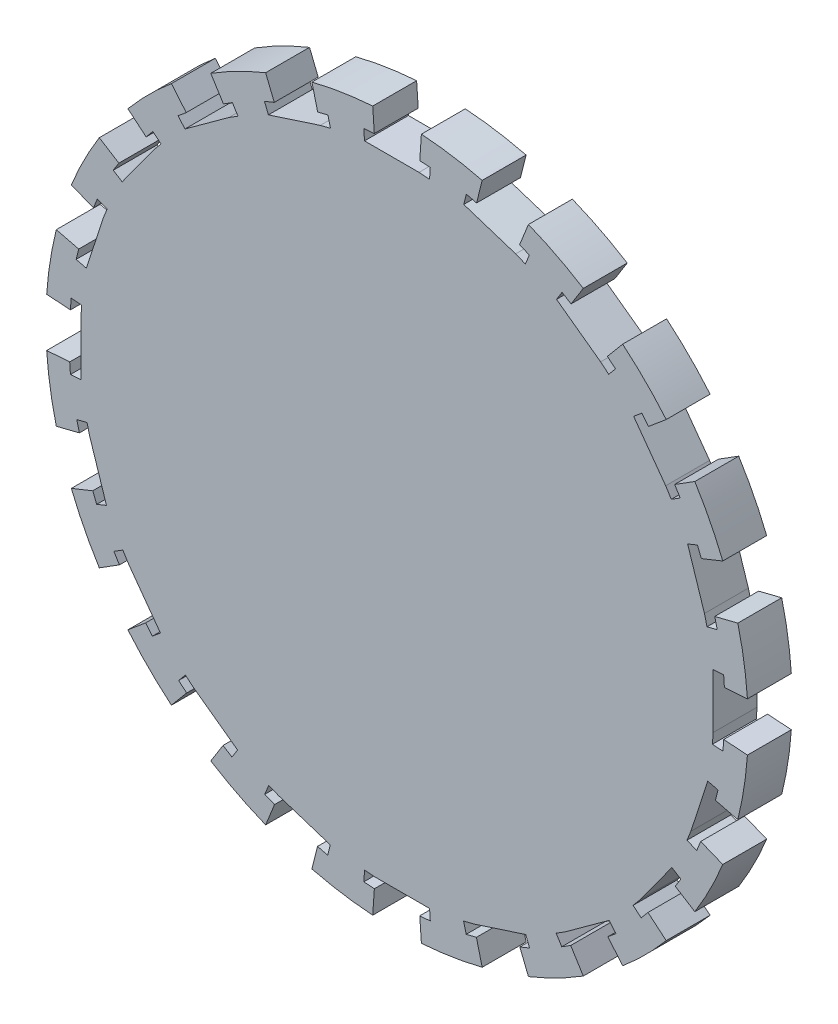
from build123d import *

# Parameters (mm, degrees)
BOSS_EXTRUDE1_DEPTH = 3.175


with BuildPart() as part:
    # Sketch1 → Boss-Extrude1 (new body)
    with BuildSketch(Plane.XY):
        with BuildLine():
            Line((-1.643964299, 23.673085901), (-1.759651006, 25.338974493))
            ThreePointArc((-1.759651006, 25.338974493), (-3.973435412, 25.087283851), (-6.156646182, 24.642558873))
            Line((-6.156646182, 24.642558873), (-5.739470481, 22.972773656))
            Line((-5.739470481, 22.972773656), (-4.998413266, 23.157917865))
            Line((-4.998413266, 23.157917865), (-4.813269057, 22.41686065))
            Line((-4.813269057, 22.41686065), (-5.554326272, 22.231716441))
            Line((-5.554326272, 22.231716441), (-8.573930711, 21.250587484))
            Line((-8.573930711, 21.250587484), (-9.302130689, 21.013980968))
            Line((-9.302130689, 21.013980968), (-9.587241728, 21.720632011))
            Line((-9.587241728, 21.720632011), (-8.878888812, 22.006429701))
            Line((-8.878888812, 22.006429701), (-9.503701294, 23.555034742))
            ThreePointArc((-9.503701294, 23.555034742), (-11.531358693, 22.631565714), (-13.470287947, 21.533957895))
            Line((-13.470287947, 21.533957895), (-12.557538268, 20.074812165))
            Line((-12.557538268, 20.074812165), (-11.909963682, 20.479894045))
            Line((-11.909963682, 20.479894045), (-11.504881803, 19.832319459))
            Line((-11.504881803, 19.832319459), (-12.152456389, 19.427237579))
            Line((-12.152456389, 19.427237579), (-14.721085346, 17.561019403))
            Line((-14.721085346, 17.561019403), (-15.340529246, 17.110967066))
            Line((-15.340529246, 17.110967066), (-15.830053138, 17.694927989))
            Line((-15.830053138, 17.694927989), (-15.244685825, 18.185630833))
            Line((-15.244685825, 18.185630833), (-16.317463083, 19.465364074))
            ThreePointArc((-16.317463083, 19.465364074), (-17.960512242, 17.960512242), (-19.465364074, 16.317463083))
            Line((-19.465364074, 16.317463083), (-18.146386717, 15.211788191))
            Line((-18.146386717, 15.211788191), (-17.655683872, 15.797155504))
            Line((-17.655683872, 15.797155504), (-17.070316559, 15.306452659))
            Line((-17.070316559, 15.306452659), (-17.561019403, 14.721085346))
            Line((-17.561019403, 14.721085346), (-19.427237579, 12.152456389))
            Line((-19.427237579, 12.152456389), (-19.877289916, 11.533012489))
            Line((-19.877289916, 11.533012489), (-20.523308653, 11.937121127))
            Line((-20.523308653, 11.937121127), (-20.118226774, 12.584695713))
            Line((-20.118226774, 12.584695713), (-21.533957895, 13.470287947))
            ThreePointArc((-21.533957895, 13.470287947), (-22.631565714, 11.531358693), (-23.555034742, 9.503701294))
            Line((-23.555034742, 9.503701294), (-21.9589404, 8.859728401))
            Line((-21.9589404, 8.859728401), (-21.67314271, 9.568081318))
            Line((-21.67314271, 9.568081318), (-20.964789794, 9.282283627))
            Line((-20.964789794, 9.282283627), (-21.250587484, 8.573930711))
            Line((-21.250587484, 8.573930711), (-22.231716441, 5.554326272))
            Line((-22.231716441, 5.554326272), (-22.468322957, 4.826126294))
            Line((-22.468322957, 4.826126294), (-23.207599723, 5.010825679))
            Line((-23.207599723, 5.010825679), (-23.022455514, 5.751882894))
            Line((-23.022455514, 5.751882894), (-24.642558873, 6.156646182))
            ThreePointArc((-24.642558873, 6.156646182), (-25.087283851, 3.973435412), (-25.338974493, 1.759651006))
            Line((-25.338974493, 1.759651006), (-23.622, 1.640416667))
            Line((-23.622, 1.640416667), (-23.569083333, 2.402416667))
            Line((-23.569083333, 2.402416667), (-22.807083333, 2.3495))
            Line((-22.807083333, 2.3495), (-22.86, 1.5875))
            Line((-22.86, 1.5875), (-22.86, -1.5875))
            Line((-22.86, -1.5875), (-22.86, -2.353174769))
            Line((-22.86, -2.353174769), (-23.620169235, -2.405964299))
            Line((-23.620169235, -2.405964299), (-23.673085901, -1.643964299))
            Line((-23.673085901, -1.643964299), (-25.338974493, -1.759651006))
            ThreePointArc((-25.338974493, -1.759651006), (-25.087283851, -3.973435412), (-24.642558873, -6.156646182))
            Line((-24.642558873, -6.156646182), (-22.972773656, -5.739470481))
            Line((-22.972773656, -5.739470481), (-23.157917865, -4.998413266))
            Line((-23.157917865, -4.998413266), (-22.41686065, -4.813269057))
            Line((-22.41686065, -4.813269057), (-22.231716441, -5.554326272))
            Line((-22.231716441, -5.554326272), (-21.250587484, -8.573930711))
            Line((-21.250587484, -8.573930711), (-21.013980968, -9.302130689))
            Line((-21.013980968, -9.302130689), (-21.720632011, -9.587241728))
            Line((-21.720632011, -9.587241728), (-22.006429701, -8.878888812))
            Line((-22.006429701, -8.878888812), (-23.555034742, -9.503701294))
            ThreePointArc((-23.555034742, -9.503701294), (-22.631565714, -11.531358693), (-21.533957895, -13.470287947))
            Line((-21.533957895, -13.470287947), (-20.074812165, -12.557538268))
            Line((-20.074812165, -12.557538268), (-20.479894045, -11.909963682))
            Line((-20.479894045, -11.909963682), (-19.832319459, -11.504881803))
            Line((-19.832319459, -11.504881803), (-19.427237579, -12.152456389))
            Line((-19.427237579, -12.152456389), (-17.561019403, -14.721085346))
            Line((-17.561019403, -14.721085346), (-17.110967066, -15.340529246))
            Line((-17.110967066, -15.340529246), (-17.694927989, -15.830053138))
            Line((-17.694927989, -15.830053138), (-18.185630833, -15.244685825))
            Line((-18.185630833, -15.244685825), (-19.465364074, -16.317463083))
            ThreePointArc((-19.465364074, -16.317463083), (-17.960512242, -17.960512242), (-16.317463083, -19.465364074))
            Line((-16.317463083, -19.465364074), (-15.211788191, -18.146386717))
            Line((-15.211788191, -18.146386717), (-15.797155504, -17.655683872))
            Line((-15.797155504, -17.655683872), (-15.306452659, -17.070316559))
            Line((-15.306452659, -17.070316559), (-14.721085346, -17.561019403))
            Line((-14.721085346, -17.561019403), (-12.152456389, -19.427237579))
            Line((-12.152456389, -19.427237579), (-11.533012489, -19.877289916))
            Line((-11.533012489, -19.877289916), (-11.937121127, -20.523308653))
            Line((-11.937121127, -20.523308653), (-12.584695713, -20.118226774))
            Line((-12.584695713, -20.118226774), (-13.470287947, -21.533957895))
            ThreePointArc((-13.470287947, -21.533957895), (-11.531358693, -22.631565714), (-9.503701294, -23.555034742))
            Line((-9.503701294, -23.555034742), (-8.859728401, -21.9589404))
            Line((-8.859728401, -21.9589404), (-9.568081318, -21.67314271))
            Line((-9.568081318, -21.67314271), (-9.282283627, -20.964789794))
            Line((-9.282283627, -20.964789794), (-8.573930711, -21.250587484))
            Line((-8.573930711, -21.250587484), (-5.554326272, -22.231716441))
            Line((-5.554326272, -22.231716441), (-4.826126294, -22.468322957))
            Line((-4.826126294, -22.468322957), (-5.010825679, -23.207599723))
            Line((-5.010825679, -23.207599723), (-5.751882894, -23.022455514))
            Line((-5.751882894, -23.022455514), (-6.156646182, -24.642558873))
            ThreePointArc((-6.156646182, -24.642558873), (-3.973435412, -25.087283851), (-1.759651006, -25.338974493))
            Line((-1.759651006, -25.338974493), (-1.640416667, -23.622))
            Line((-1.640416667, -23.622), (-2.402416667, -23.569083333))
            Line((-2.402416667, -23.569083333), (-2.3495, -22.807083333))
            Line((-2.3495, -22.807083333), (-1.5875, -22.86))
            Line((-1.5875, -22.86), (1.5875, -22.86))
            Line((1.5875, -22.86), (2.353174769, -22.86))
            Line((2.353174769, -22.86), (2.405964299, -23.620169235))
            Line((2.405964299, -23.620169235), (1.643964299, -23.673085901))
            Line((1.643964299, -23.673085901), (1.759651006, -25.338974493))
            ThreePointArc((1.759651006, -25.338974493), (3.973435412, -25.087283851), (6.156646182, -24.642558873))
            Line((6.156646182, -24.642558873), (5.739470481, -22.972773656))
            Line((5.739470481, -22.972773656), (4.998413266, -23.157917865))
            Line((4.998413266, -23.157917865), (4.813269057, -22.41686065))
            Line((4.813269057, -22.41686065), (5.554326272, -22.231716441))
            Line((5.554326272, -22.231716441), (8.573930711, -21.250587484))
            Line((8.573930711, -21.250587484), (9.302130689, -21.013980968))
            Line((9.302130689, -21.013980968), (9.587241728, -21.720632011))
            Line((9.587241728, -21.720632011), (8.878888812, -22.006429701))
            Line((8.878888812, -22.006429701), (9.503701294, -23.555034742))
            ThreePointArc((9.503701294, -23.555034742), (11.531358693, -22.631565714), (13.470287947, -21.533957895))
            Line((13.470287947, -21.533957895), (12.557538268, -20.074812165))
            Line((12.557538268, -20.074812165), (11.909963682, -20.479894045))
            Line((11.909963682, -20.479894045), (11.504881803, -19.832319459))
            Line((11.504881803, -19.832319459), (12.152456389, -19.427237579))
            Line((12.152456389, -19.427237579), (14.721085346, -17.561019403))
            Line((14.721085346, -17.561019403), (15.340529246, -17.110967066))
            Line((15.340529246, -17.110967066), (15.830053138, -17.694927989))
            Line((15.830053138, -17.694927989), (15.244685825, -18.185630833))
            Line((15.244685825, -18.185630833), (16.317463083, -19.465364074))
            ThreePointArc((16.317463083, -19.465364074), (17.960512242, -17.960512242), (19.465364074, -16.317463083))
            Line((19.465364074, -16.317463083), (18.146386717, -15.211788191))
            Line((18.146386717, -15.211788191), (17.655683872, -15.797155504))
            Line((17.655683872, -15.797155504), (17.070316559, -15.306452659))
            Line((17.070316559, -15.306452659), (17.561019403, -14.721085346))
            Line((17.561019403, -14.721085346), (19.427237579, -12.152456389))
            Line((19.427237579, -12.152456389), (19.877289916, -11.533012489))
            Line((19.877289916, -11.533012489), (20.523308653, -11.937121127))
            Line((20.523308653, -11.937121127), (20.118226774, -12.584695713))
            Line((20.118226774, -12.584695713), (21.533957895, -13.470287947))
            ThreePointArc((21.533957895, -13.470287947), (22.631565714, -11.531358693), (23.555034742, -9.503701294))
            Line((23.555034742, -9.503701294), (21.9589404, -8.859728401))
            Line((21.9589404, -8.859728401), (21.67314271, -9.568081318))
            Line((21.67314271, -9.568081318), (20.964789794, -9.282283627))
            Line((20.964789794, -9.282283627), (21.250587484, -8.573930711))
            Line((21.250587484, -8.573930711), (22.231716441, -5.554326272))
            Line((22.231716441, -5.554326272), (22.468322957, -4.826126294))
            Line((22.468322957, -4.826126294), (23.207599723, -5.010825679))
            Line((23.207599723, -5.010825679), (23.022455514, -5.751882894))
            Line((23.022455514, -5.751882894), (24.642558873, -6.156646182))
            ThreePointArc((24.642558873, -6.156646182), (25.087283851, -3.973435412), (25.338974493, -1.759651006))
            Line((25.338974493, -1.759651006), (23.622, -1.640416667))
            Line((23.622, -1.640416667), (23.569083333, -2.402416667))
            Line((23.569083333, -2.402416667), (22.807083333, -2.3495))
            Line((22.807083333, -2.3495), (22.86, -1.5875))
            Line((22.86, -1.5875), (22.86, 1.5875))
            Line((22.86, 1.5875), (22.86, 2.353174769))
            Line((22.86, 2.353174769), (23.620169235, 2.405964299))
            Line((23.620169235, 2.405964299), (23.673085901, 1.643964299))
            Line((23.673085901, 1.643964299), (25.338974493, 1.759651006))
            ThreePointArc((25.338974493, 1.759651006), (25.087283851, 3.973435412), (24.642558873, 6.156646182))
            Line((24.642558873, 6.156646182), (22.972773656, 5.739470481))
            Line((22.972773656, 5.739470481), (23.157917865, 4.998413266))
            Line((23.157917865, 4.998413266), (22.41686065, 4.813269057))
            Line((22.41686065, 4.813269057), (22.231716441, 5.554326272))
            Line((22.231716441, 5.554326272), (21.250587484, 8.573930711))
            Line((21.250587484, 8.573930711), (21.013980968, 9.302130689))
            Line((21.013980968, 9.302130689), (21.720632011, 9.587241728))
            Line((21.720632011, 9.587241728), (22.006429701, 8.878888812))
            Line((22.006429701, 8.878888812), (23.555034742, 9.503701294))
            ThreePointArc((23.555034742, 9.503701294), (22.631565714, 11.531358693), (21.533957895, 13.470287947))
            Line((21.533957895, 13.470287947), (20.074812165, 12.557538268))
            Line((20.074812165, 12.557538268), (20.479894045, 11.909963682))
            Line((20.479894045, 11.909963682), (19.832319459, 11.504881803))
            Line((19.832319459, 11.504881803), (19.427237579, 12.152456389))
            Line((19.427237579, 12.152456389), (17.561019403, 14.721085346))
            Line((17.561019403, 14.721085346), (17.110967066, 15.340529246))
            Line((17.110967066, 15.340529246), (17.694927989, 15.830053138))
            Line((17.694927989, 15.830053138), (18.185630833, 15.244685825))
            Line((18.185630833, 15.244685825), (19.465364074, 16.317463083))
            ThreePointArc((19.465364074, 16.317463083), (17.960512242, 17.960512242), (16.317463083, 19.465364074))
            Line((16.317463083, 19.465364074), (15.211788191, 18.146386717))
            Line((15.211788191, 18.146386717), (15.797155504, 17.655683872))
            Line((15.797155504, 17.655683872), (15.306452659, 17.070316559))
            Line((15.306452659, 17.070316559), (14.721085346, 17.561019403))
            Line((14.721085346, 17.561019403), (12.152456389, 19.427237579))
            Line((12.152456389, 19.427237579), (11.533012489, 19.877289916))
            Line((11.533012489, 19.877289916), (11.937121127, 20.523308653))
            Line((11.937121127, 20.523308653), (12.584695713, 20.118226774))
            Line((12.584695713, 20.118226774), (13.470287947, 21.533957895))
            ThreePointArc((13.470287947, 21.533957895), (11.531358693, 22.631565714), (9.503701294, 23.555034742))
            Line((9.503701294, 23.555034742), (8.859728401, 21.9589404))
            Line((8.859728401, 21.9589404), (9.568081318, 21.67314271))
            Line((9.568081318, 21.67314271), (9.282283627, 20.964789794))
            Line((9.282283627, 20.964789794), (8.573930711, 21.250587484))
            Line((8.573930711, 21.250587484), (5.554326272, 22.231716441))
            Line((5.554326272, 22.231716441), (4.826126294, 22.468322957))
            Line((4.826126294, 22.468322957), (5.010825679, 23.207599723))
            Line((5.010825679, 23.207599723), (5.751882894, 23.022455514))
            Line((5.751882894, 23.022455514), (6.156646182, 24.642558873))
            ThreePointArc((6.156646182, 24.642558873), (3.973435412, 25.087283851), (1.759651006, 25.338974493))
            Line((1.759651006, 25.338974493), (1.640416667, 23.622))
            Line((1.640416667, 23.622), (2.402416667, 23.569083333))
            Line((2.402416667, 23.569083333), (2.3495, 22.807083333))
            Line((2.3495, 22.807083333), (1.5875, 22.86))
            Line((1.5875, 22.86), (0, 22.86))
            Line((0, 22.86), (-1.5875, 22.86))
            Line((-1.5875, 22.86), (-2.353174769, 22.86))
            Line((-2.353174769, 22.86), (-2.405964299, 23.620169235))
            Line((-2.405964299, 23.620169235), (-1.643964299, 23.673085901))
        make_face()
    extrude(amount=BOSS_EXTRUDE1_DEPTH)


solid = part.part
